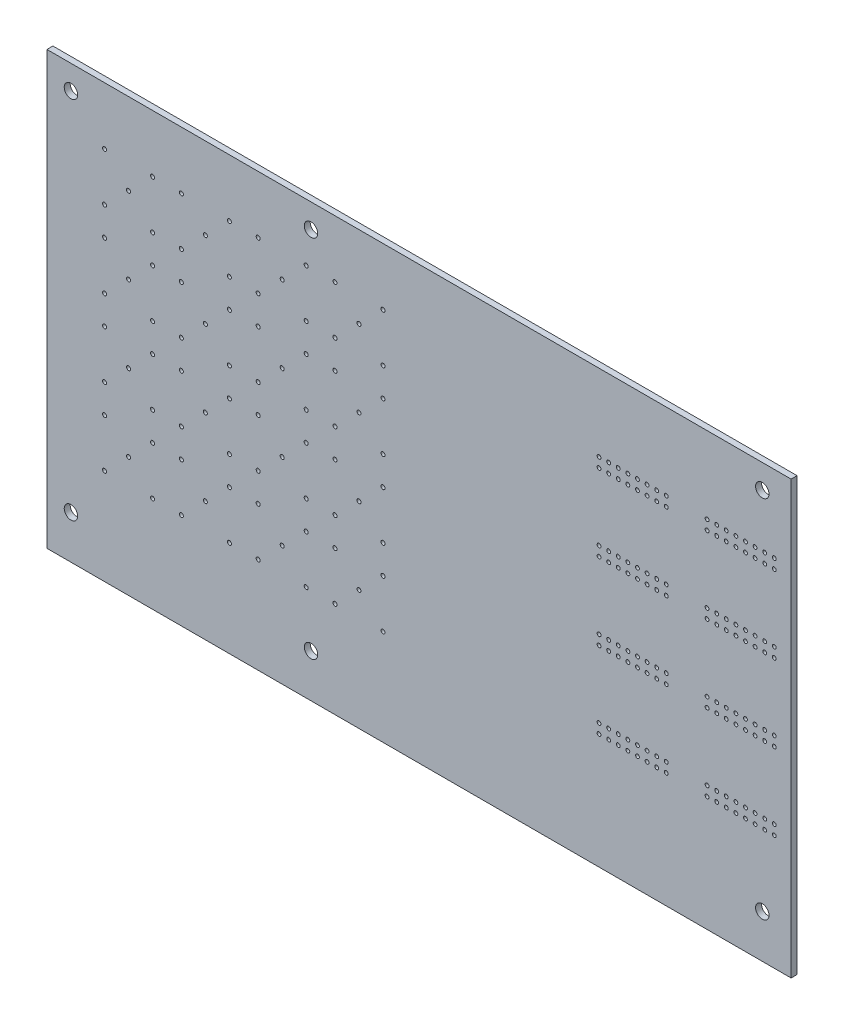
from build123d import *

# Parameters (mm, degrees)
SKETCH1_W                = 196.85
SKETCH1_H                = 114.3
PCB_OUTLINE_DEPTH        = 1.5748
MOUNTING_HOLES_R         = 1.778
MOUNTING_HOLES_CUT_DEPTH = 2.54
SKETCH2_R                = 0.5334
CUT_EXTRUDE1_DEPTH       = 1.5748
LPATTERN1_COUNT          = 4
LPATTERN1_PITCH          = 20.32
LPATTERN1_COUNT_DIR2     = 4
LPATTERN1_PITCH_DIR2     = 20.32
SKETCH3_R                = 0.508
DIO_SEED_DEPTH           = 1.5748
DIO_PATTERN_COUNT        = 2
DIO_PATTERN_PITCH        = 28.575
DIO_PATTERN_COUNT_DIR2   = 4
DIO_PATTERN_PITCH_DIR2   = 20.32


with BuildPart() as part:
    # Sketch1 → PCB outline (new body)
    with BuildSketch(Plane.XY):
        with Locations((98.425, -57.15)):
            Rectangle(SKETCH1_W, SKETCH1_H)
    extrude(amount=PCB_OUTLINE_DEPTH)

    # mounting holes → mounting holes cut (cut)
    with BuildSketch(Plane.XY.offset(1.5748)):
        with Locations((6.35, -6.35)):
            Circle(MOUNTING_HOLES_R)
        with Locations((69.85, -6.35)):
            Circle(MOUNTING_HOLES_R)
        with Locations((189.23, -6.35)):
            Circle(MOUNTING_HOLES_R)
        with Locations((189.23, -102.87)):
            Circle(MOUNTING_HOLES_R)
        with Locations((69.85, -102.87)):
            Circle(MOUNTING_HOLES_R)
        with Locations((6.35, -102.87)):
            Circle(MOUNTING_HOLES_R)
    extrude(amount=-MOUNTING_HOLES_CUT_DEPTH, mode=Mode.SUBTRACT)

    # Sketch2 → Cut-Extrude1 (cut)
    with BuildSketch(Plane.XY.offset(1.5748)):
        with Locations((21.59, -21.59)):
            Circle(SKETCH2_R)
        with Locations((27.94, -15.19)):
            Circle(SKETCH2_R)
        with Locations((15.24, -15.19)):
            Circle(SKETCH2_R)
        with Locations((27.94, -27.94)):
            Circle(SKETCH2_R)
        with Locations((15.24, -27.94)):
            Circle(SKETCH2_R)
    cut_extrude1 = extrude(amount=-CUT_EXTRUDE1_DEPTH, mode=Mode.SUBTRACT)

    # LPattern1: Cut-Extrude1 4 × 4
    with Locations(*[(i * LPATTERN1_PITCH, -j * LPATTERN1_PITCH_DIR2, 0) for i in range(LPATTERN1_COUNT) for j in range(LPATTERN1_COUNT_DIR2) if (i, j) != (0, 0)]):
        add(cut_extrude1, mode=Mode.SUBTRACT)

    # Sketch3 → DIO seed (cut)
    with BuildSketch(Plane.XY.offset(1.5748)):
        with Locations((146.05, -20.32)):
            Circle(SKETCH3_R)
        with Locations((148.59, -20.32)):
            Circle(SKETCH3_R)
        with Locations((151.13, -20.32)):
            Circle(SKETCH3_R)
        with Locations((153.67, -20.32)):
            Circle(SKETCH3_R)
        with Locations((156.21, -20.32)):
            Circle(SKETCH3_R)
        with Locations((158.75, -20.32)):
            Circle(SKETCH3_R)
        with Locations((161.29, -20.32)):
            Circle(SKETCH3_R)
        with Locations((163.83, -20.32)):
            Circle(SKETCH3_R)
        with Locations((146.05, -22.86)):
            Circle(SKETCH3_R)
        with Locations((148.59, -22.86)):
            Circle(SKETCH3_R)
        with Locations((151.13, -22.86)):
            Circle(SKETCH3_R)
        with Locations((153.67, -22.86)):
            Circle(SKETCH3_R)
        with Locations((156.21, -22.86)):
            Circle(SKETCH3_R)
        with Locations((158.75, -22.86)):
            Circle(SKETCH3_R)
        with Locations((161.29, -22.86)):
            Circle(SKETCH3_R)
        with Locations((163.83, -22.86)):
            Circle(SKETCH3_R)
    dio_seed = extrude(amount=-DIO_SEED_DEPTH, mode=Mode.SUBTRACT)

    # DIO pattern: DIO seed 2 × 4
    with Locations(*[(i * DIO_PATTERN_PITCH, -j * DIO_PATTERN_PITCH_DIR2, 0) for i in range(DIO_PATTERN_COUNT) for j in range(DIO_PATTERN_COUNT_DIR2) if (i, j) != (0, 0)]):
        add(dio_seed, mode=Mode.SUBTRACT)


solid = part.part
